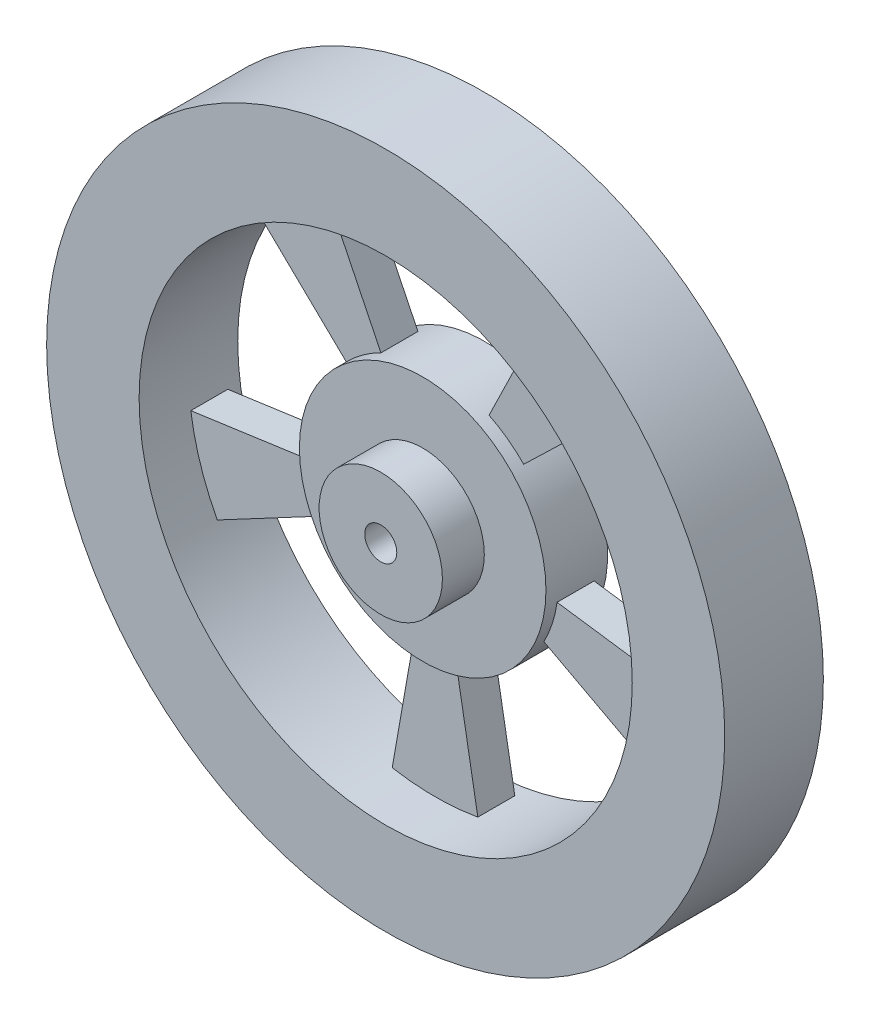
from build123d import *
from build123d.topology import SkipClean

# Parameters (mm, degrees)
SKETCH1_R           = 17.4625
BOSS_EXTRUDE1_DEPTH = 5.08
CUT_EXTRUDE1_DEPTH  = 5.08
SKETCH3_R           = 3.175
BOSS_EXTRUDE2_DEPTH = 0.254
SKETCH4_R           = 0.8255
CUT_EXTRUDE2_DEPTH  = 6.334
SKETCH5_R           = 12.7
SKETCH5_R_2         = 6.35
CUT_EXTRUDE3_DEPTH  = 2.54
SKETCH6_R           = 12.7
SKETCH6_R_2         = 6.35
CUT_EXTRUDE4_DEPTH  = 0.635
SKETCH7_R           = 6.35
SKETCH7_R_2         = 3.175
CUT_EXTRUDE5_DEPTH  = 1.905


with BuildPart() as part:
    # Sketch1 → Boss-Extrude1 (new body)
    with BuildSketch(Plane.XY):
        Circle(SKETCH1_R)
    extrude(amount=BOSS_EXTRUDE1_DEPTH)

    # Sketch2 → Cut-Extrude1 (cut)
    with BuildSketch(Plane(origin=(0, 0, 0), x_dir=(-1, 0, 0), z_dir=(0, 0, -1))):
        with BuildLine():
            Line((2.205331856, -12.507058463), (1.102665928, -6.253529232))
            ThreePointArc((1.102665928, -6.253529232), (3.732436352, -5.137257914), (5.606717215, -2.981144424))
            Line((5.606717215, -2.981144424), (11.213434429, -5.962288847))
            ThreePointArc((11.213434429, -5.962288847), (7.464872704, -10.274515829), (2.205331856, -12.507058463))
        make_face()
        with BuildLine():
            Line((-1.102665928, -6.253529232), (-2.205331856, -12.507058463))
            ThreePointArc((-2.205331856, -12.507058463), (-7.464872704, -10.274515829), (-11.213434429, -5.962288847))
            Line((-11.213434429, -5.962288847), (-5.606717215, -2.981144424))
            ThreePointArc((-5.606717215, -2.981144424), (-3.732436352, -5.137257914), (-1.102665928, -6.253529232))
        make_face()
        with BuildLine():
            Line((-6.288202237, -0.883749191), (-12.576404473, -1.767498382))
            ThreePointArc((-12.576404473, -1.767498382), (-12.078417757, 3.924515829), (-9.135615464, 8.822161305))
            Line((-9.135615464, 8.822161305), (-4.567807732, 4.411080652))
            ThreePointArc((-4.567807732, 4.411080652), (-6.039208878, 1.962257914), (-6.288202237, -0.883749191))
        make_face()
        with BuildLine():
            Line((-2.783656782, 5.707342194), (-5.567313564, 11.414684388))
            ThreePointArc((-5.567313564, 11.414684388), (0, 12.7), (5.567313564, 11.414684388))
            Line((5.567313564, 11.414684388), (2.783656782, 5.707342194))
            ThreePointArc((2.783656782, 5.707342194), (0, 6.35), (-2.783656782, 5.707342194))
        make_face()
        with BuildLine():
            Line((4.567807732, 4.411080652), (9.135615464, 8.822161305))
            ThreePointArc((9.135615464, 8.822161305), (12.078417757, 3.924515829), (12.576404473, -1.767498382))
            Line((12.576404473, -1.767498382), (6.288202237, -0.883749191))
            ThreePointArc((6.288202237, -0.883749191), (6.039208878, 1.962257914), (4.567807732, 4.411080652))
        make_face()
    extrude(amount=-CUT_EXTRUDE1_DEPTH, mode=Mode.SUBTRACT)

    # Sketch3 → Boss-Extrude2 (add)
    with BuildSketch(Plane.XY.offset(5.08)):
        Circle(SKETCH3_R)
    extrude(amount=BOSS_EXTRUDE2_DEPTH)

    # Sketch4 → Cut-Extrude2 (cut, through all)
    with BuildSketch(Plane.XY.offset(5.334)):
        Circle(SKETCH4_R)
    extrude(amount=-CUT_EXTRUDE2_DEPTH, mode=Mode.SUBTRACT)

    # Sketch5 → Cut-Extrude3 (cut)
    with BuildSketch(Plane.XY.offset(5.08)):
        with Locations(Location((0, 0, 0), (0, 0, 180))):  # turned: the seam where the file's is
            Circle(SKETCH5_R)
        with Locations(Location((0, 0, 0), (0, 0, 180))):  # turned: the seam where the file's is
            Circle(SKETCH5_R_2, mode=Mode.SUBTRACT)
    extrude(amount=-CUT_EXTRUDE3_DEPTH, mode=Mode.SUBTRACT)

    # Sketch6 → Cut-Extrude4 (cut)
    with SkipClean():  # keep this step's faces unmerged: merging them makes the solid invalid here
        with BuildSketch(Plane(origin=(0, 0, 0), x_dir=(-1, 0, 0), z_dir=(0, 0, -1))):
            Circle(SKETCH6_R)
            Circle(SKETCH6_R_2, mode=Mode.SUBTRACT)
        extrude(amount=-CUT_EXTRUDE4_DEPTH, mode=Mode.SUBTRACT)

    # Sketch7 → Cut-Extrude5 (cut)
    with SkipClean():  # keep this step's faces unmerged: merging them makes the solid invalid here
        with BuildSketch(Plane.XY.offset(5.08)):
            with Locations(Location((0, 0, 0), (0, 0, 180))):  # turned: the seam where the file's is
                Circle(SKETCH7_R)
            Circle(SKETCH7_R_2, mode=Mode.SUBTRACT)
        extrude(amount=-CUT_EXTRUDE5_DEPTH, mode=Mode.SUBTRACT)


solid = part.part
